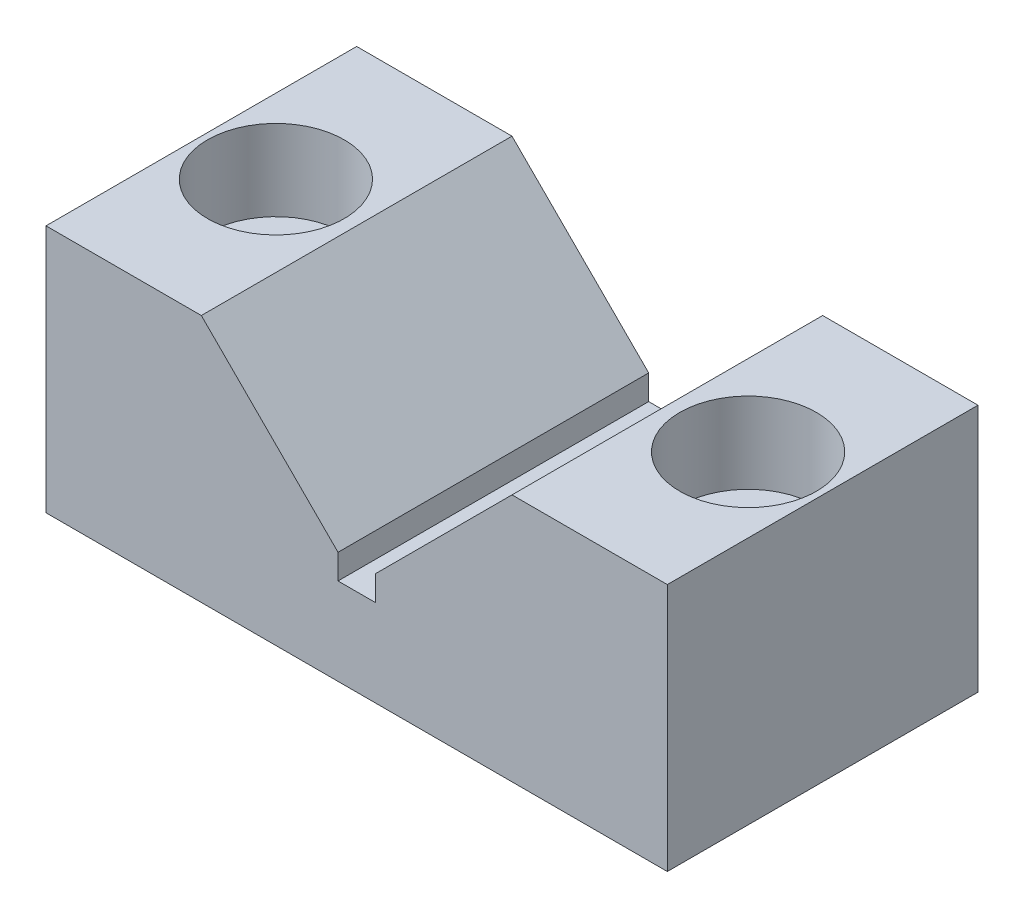
from build123d import *

# Parameters (mm, degrees)
BOSS_EXTRUDE1_DEPTH      = 12.5
BOSS_EXTRUDE1_DEPTH_BACK = 12.5
SKETCH2_R                = 3.25
CUT_EXTRUDE1_DEPTH       = 35.369317712
SKETCH3_R                = 5.5
CUT_EXTRUDE2_DEPTH       = 6.5


with BuildPart() as part:
    # Sketch1 → Boss-Extrude1 (new, two sides: drawn at the far end of the back side and taken through both)
    with BuildSketch(Plane.XY.offset(-BOSS_EXTRUDE1_DEPTH_BACK)):
        Polygon((-25, 0), (25, 0), (25, 20), (12.5, 20), (1.5, 9), (1.5, 7), (-1.5, 7), (-1.5, 9), (-12.5, 20), (-25, 20), align=None)
    extrude(amount=BOSS_EXTRUDE1_DEPTH + BOSS_EXTRUDE1_DEPTH_BACK)

    # Sketch2 → Cut-Extrude1 (cut, through all)
    with BuildSketch(Plane(origin=(0, 20, 0), x_dir=(-1, 0, 0), z_dir=(0, 1, 0))):
        with Locations((19, 0)):
            Circle(SKETCH2_R)
        with Locations((-19, 0)):
            Circle(SKETCH2_R)
    extrude(amount=-CUT_EXTRUDE1_DEPTH, mode=Mode.SUBTRACT)

    # Sketch3 → Cut-Extrude2 (cut)
    with BuildSketch(Plane(origin=(0, 20, 0), x_dir=(-1, 0, 0), z_dir=(0, 1, 0))):
        with Locations((19, 0)):
            Circle(SKETCH3_R)
        with Locations((-19, 0)):
            Circle(SKETCH3_R)
    extrude(amount=-CUT_EXTRUDE2_DEPTH, mode=Mode.SUBTRACT)


solid = part.part
